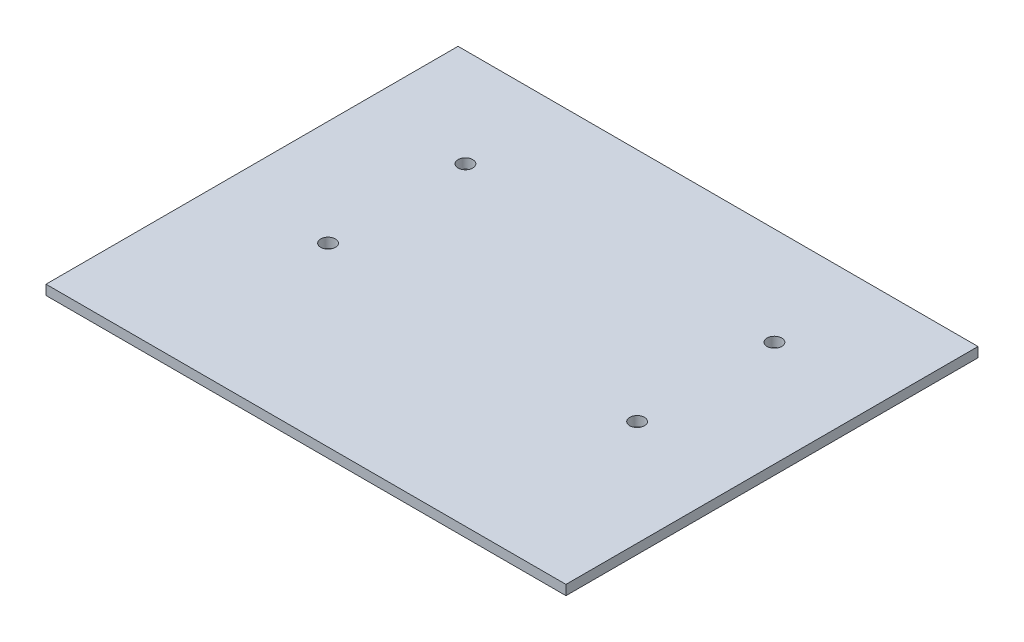
from build123d import *

# Parameters (mm, degrees)
SKETCH1_W           = 106
SKETCH1_H           = 84
SKETCH1_R           = 1.5
BOSS_EXTRUDE1_DEPTH = 2


with BuildPart() as part:
    # Sketch1 → Boss-Extrude1 (new body)
    with BuildSketch(Plane(origin=(0, 0, 0), x_dir=(1, 0, 0), z_dir=(0, 1, 0))):
        with Locations((53, 42)):
            Rectangle(SKETCH1_W, SKETCH1_H)
        with Locations((84.5, 64)):
            Circle(SKETCH1_R, mode=Mode.SUBTRACT)
        with Locations((84.5, 36)):
            Circle(SKETCH1_R, mode=Mode.SUBTRACT)
        with Locations((21.5, 36)):
            Circle(SKETCH1_R, mode=Mode.SUBTRACT)
        with Locations((21.5, 64)):
            Circle(SKETCH1_R, mode=Mode.SUBTRACT)
    extrude(amount=BOSS_EXTRUDE1_DEPTH)


solid = part.part
